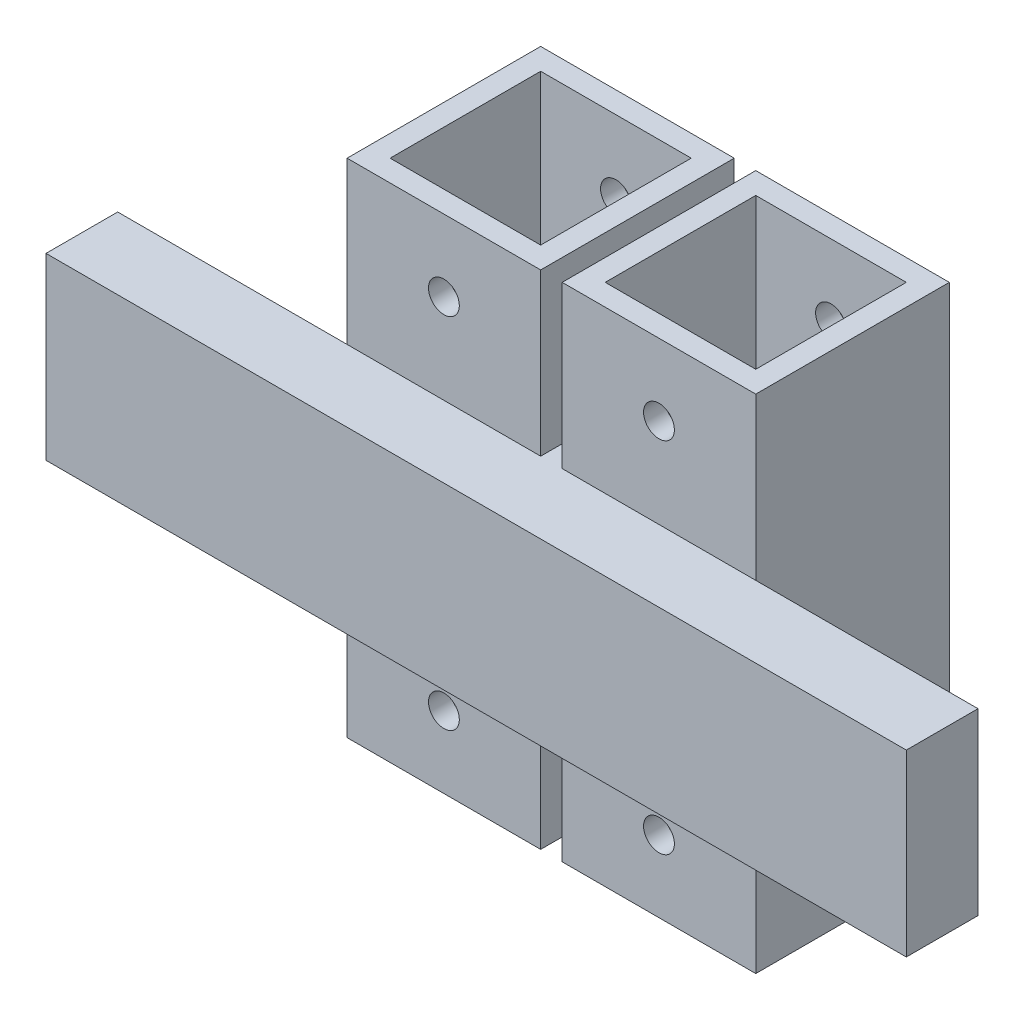
from build123d import *

# Parameters (mm, degrees)
SKETCH1_W             = 27
SKETCH1_H             = 27
SKETCH1_W_2           = 21
SKETCH1_H_2           = 21
BOSS_EXTRUDE1_DEPTH   = 70
BOSS_EXTRUDE1_2_DEPTH = 70
SKETCH2_W             = 120
SKETCH2_H             = 25
BOSS_EXTRUDE2_DEPTH   = 10
SKETCH3_W             = 3
SKETCH3_H             = 25
BOSS_EXTRUDE3_DEPTH   = 27
SKETCH4_R             = 2.15
CUT_EXTRUDE1_DEPTH    = 38


with BuildPart() as part:
    # Sketch1 → Boss-Extrude1 (new body)
    with BuildSketch(Plane(origin=(0, 0, 0), x_dir=(1, 0, 0), z_dir=(0, 1, 0))):
        with Locations((13.5, 13.5)):
            Rectangle(SKETCH1_W, SKETCH1_H)
        with Locations((13.5, 13.5)):
            Rectangle(SKETCH1_W_2, SKETCH1_H_2, mode=Mode.SUBTRACT)
    extrude(amount=BOSS_EXTRUDE1_DEPTH)



with BuildPart() as body_2:
    # Sketch1 → Boss-Extrude1 2 (new body)
    with BuildSketch(Plane(origin=(0, 0, 0), x_dir=(1, 0, 0), z_dir=(0, 1, 0))):
        with Locations((-16.5, 13.5)):
            Rectangle(SKETCH1_W, SKETCH1_H)
        with Locations((-16.5, 13.5)):
            Rectangle(SKETCH1_W_2, SKETCH1_H_2, mode=Mode.SUBTRACT)
    extrude(amount=BOSS_EXTRUDE1_2_DEPTH)


with BuildPart() as part_1:
    add(part.part)

    add(body_2.part)  # Boss-Extrude2 merges body 2
    # Sketch2 → Boss-Extrude2 (add)
    with BuildSketch(Plane.XY):
        with Locations((-2, 35)):
            Rectangle(SKETCH2_W, SKETCH2_H)
    extrude(amount=BOSS_EXTRUDE2_DEPTH)

    # Sketch3 → Boss-Extrude3 (add)
    with BuildSketch(Plane(origin=(0, 0, -27), x_dir=(-1, 0, 0), z_dir=(0, 0, -1))):
        with Locations((1.5, 35)):
            Rectangle(SKETCH3_W, SKETCH3_H)
    extrude(amount=-BOSS_EXTRUDE3_DEPTH)

    # Sketch4 → Cut-Extrude1 (cut, through all)
    with BuildSketch(Plane(origin=(0, 0, -27), x_dir=(-1, 0, 0), z_dir=(0, 0, -1))):
        with Locations((-13.5, 60)):
            Circle(SKETCH4_R)
        with Locations((16.5, 60)):
            Circle(SKETCH4_R)
        with Locations((-13.5, 10)):
            Circle(SKETCH4_R)
        with Locations((16.5, 10)):
            Circle(SKETCH4_R)
    extrude(amount=-CUT_EXTRUDE1_DEPTH, mode=Mode.SUBTRACT)


solid = part_1.part
